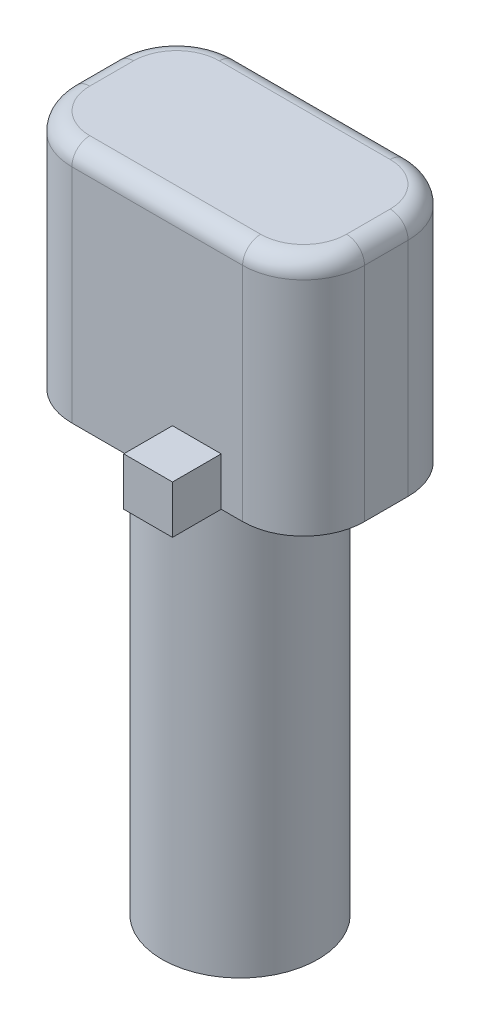
from build123d import *

# Parameters (mm, degrees)
SKETCH1_R           = 3.25
BOSS_EXTRUDE1_DEPTH = 17.686
SKETCH3_W           = 12.2
SKETCH3_H           = 6.9
BOSS_EXTRUDE2_DEPTH = 10
FILLET1_R           = 2.54
FILLET2_R           = 0.75
SKETCH5_W           = 2.032
SKETCH5_H           = 2.032
BOSS_EXTRUDE3_DEPTH = 2


with BuildPart() as part:
    # Sketch1 → Boss-Extrude1 (new body)
    with BuildSketch(Plane(origin=(0, 0, 0), x_dir=(1, 0, 0), z_dir=(0, 1, 0))):
        Circle(SKETCH1_R)
    extrude(amount=BOSS_EXTRUDE1_DEPTH)

    # Sketch3 → Boss-Extrude2 (add)
    with BuildSketch(Plane(origin=(0, 17.686, 0), x_dir=(1, 0, 0), z_dir=(0, 1, 0))):
        Rectangle(SKETCH3_W, SKETCH3_H)
    extrude(amount=BOSS_EXTRUDE2_DEPTH)

    # Fillet1
    fillet1_edges = [part.edges().sort_by_distance(p)[0] for p in [
        (6.1, 22.686, 3.45),
        (6.1, 22.686, -3.45),
        (-6.1, 22.686, -3.45),
        (-6.1, 22.686, 3.45),
    ]]
    fillet(fillet1_edges, radius=FILLET1_R)

    # Fillet2
    fillet2_edges = [part.edges().sort_by_distance(p)[0] for p in [
        (-6.1, 27.686, 0),
        (0, 27.686, -3.45),
        (6.1, 27.686, 0),
        (0, 27.686, 3.45),
        (-5.356051224, 27.686, 2.706051224),
        (5.356051224, 27.686, 2.706051224),
        (5.356051224, 27.686, -2.706051224),
        (-5.356051224, 27.686, -2.706051224),
    ]]
    fillet(fillet2_edges, radius=FILLET2_R)

    # Sketch5 → Boss-Extrude3 (add)
    with BuildSketch(Plane.XZ.offset(-17.686)):
        with Locations((-2.286, -4.466)):
            Rectangle(SKETCH5_W, SKETCH5_H)
        with Locations((1.651, 4.466)):
            Rectangle(SKETCH5_W, SKETCH5_H)
    extrude(amount=-BOSS_EXTRUDE3_DEPTH)


solid = part.part
